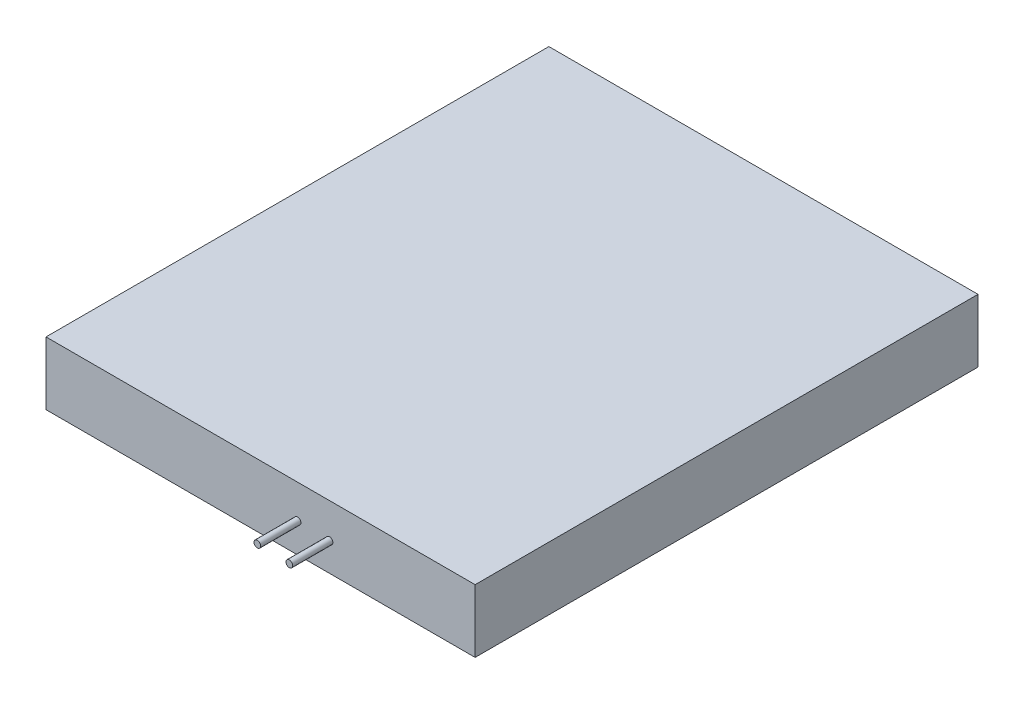
from build123d import *

# Parameters (mm, degrees)
SKETCH1_W           = 64
SKETCH1_H           = 75
BOSS_EXTRUDE1_DEPTH = 9.4
SKETCH3_R           = 0.5
BOSS_EXTRUDE2_DEPTH = 6


with BuildPart() as part:
    # Sketch1 → Boss-Extrude1 (new body)
    with BuildSketch(Plane(origin=(0, 0, 0), x_dir=(1, 0, 0), z_dir=(0, 1, 0))):
        with Locations((32, 37.5)):
            Rectangle(SKETCH1_W, SKETCH1_H)
    extrude(amount=BOSS_EXTRUDE1_DEPTH)

    # Sketch3 → Boss-Extrude2 (add)
    with BuildSketch(Plane(origin=(13.525948084, 0, 0), x_dir=(1, 0, 0), z_dir=(0, 0, 1))):
        with Locations((23.990000312, 4.397240371)):
            Circle(SKETCH3_R)
        with Locations((28.759444519, 4.234135385)):
            Circle(SKETCH3_R)
    extrude(amount=BOSS_EXTRUDE2_DEPTH)


solid = part.part
